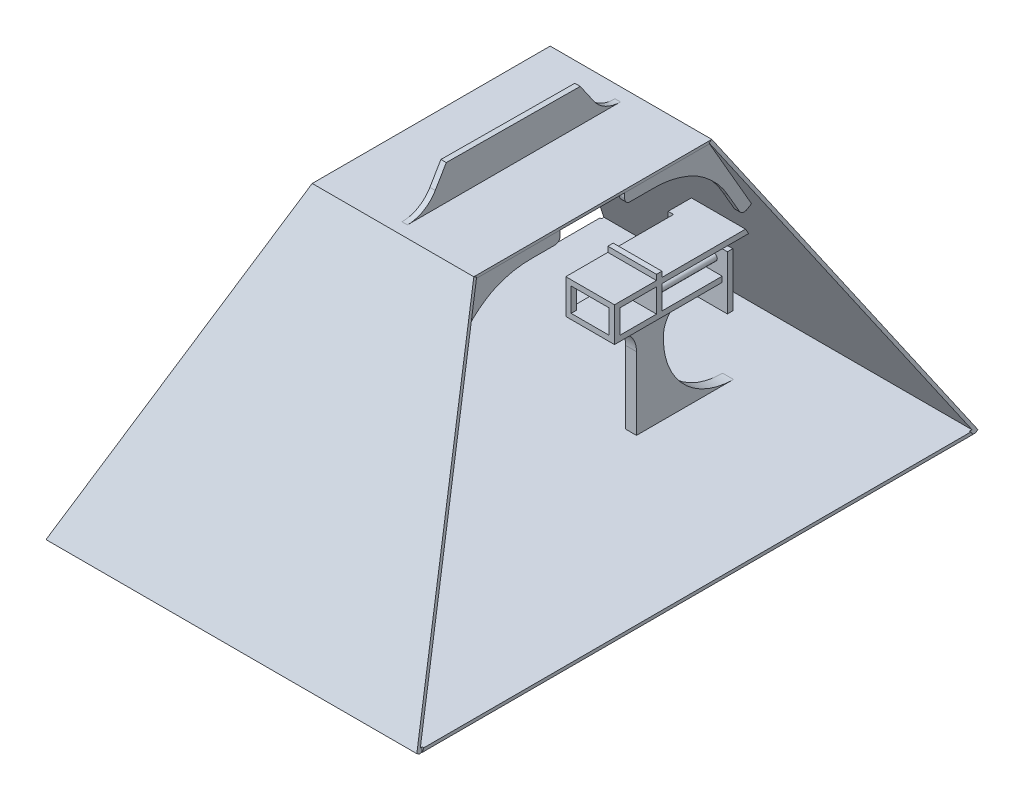
from build123d import *

# Parameters (mm, degrees)
SKETCH3_W                       = 344.153207785
SKETCH3_H                       = 300
BOSS_EXTRUDE1_DEPTH             = 3
BOSS_EXTRUDE2_REACH             = 263.308
SKETCH4_W                       = 5
SKETCH4_H                       = 100
BOSS_EXTRUDE3_REACH             = 104.598
SKETCH5_W                       = 45.211946407
SKETCH5_H                       = 5
BOSS_EXTRUDE3_DIRECTION_2_DEPTH = 100
SKETCH6_W                       = 45.211946407
SKETCH6_H                       = 5
BOSS_EXTRUDE4_DEPTH             = 100
SKETCH7_W                       = 5
SKETCH7_H                       = 50
BOSS_EXTRUDE5_DEPTH             = 50
SKETCH8_W                       = 45.211946407
SKETCH8_H                       = 5
BOSS_EXTRUDE6_DEPTH             = 5
BOSS_EXTRUDE6_DEPTH_BACK        = 27
BOSS_EXTRUDE7_DEPTH             = 3
SKETCH10_R                      = 3
BOSS_EXTRUDE8_DEPTH             = 61
CUT_EXTRUDE3_DEPTH              = 5
CUT_EXTRUDE6_DEPTH              = 5
CUT_EXTRUDE7_DEPTH              = 5
BOSS_EXTRUDE12_REACH            = 105.802
SKETCH25_W                      = 10
SKETCH25_H                      = 25
FILLET4_R                       = 65
SKETCH26_W                      = 37
SKETCH26_H                      = 10
BOSS_EXTRUDE13_DEPTH            = 10
FILLET5_R                       = 23.5
SKETCH27_W                      = 30
SKETCH27_H                      = 10
BOSS_EXTRUDE14_DEPTH            = 10
FILLET6_R                       = 23.5
FILLET7_R                       = 5
SKETCH29_W                      = 5
SKETCH29_H                      = 5
BOSS_EXTRUDE15_DEPTH            = 27
BODY_MOVE_COPY5_ANGLE           = 180
SKETCH30_W                      = 150
SKETCH30_H                      = 220.866025403
BOSS_EXTRUDE16_DEPTH            = 2.5
BOSS_EXTRUDE17_DEPTH            = 5
BOSS_EXTRUDE18_DEPTH            = 5
SKETCH36_W                      = 50
SKETCH36_H                      = 50
BOSS_EXTRUDE19_DEPTH            = 10
SKETCH37_W                      = 5
SKETCH37_H                      = 164.861239663
BOSS_EXTRUDE20_DEPTH            = 70
CUT_EXTRUDE8_DEPTH              = 170.576603893
CUT_EXTRUDE8_DEPTH_BACK         = 175.576603893
FILLET8_R                       = 30
FILLET9_R                       = 30
BOSS_EXTRUDE21_DEPTH            = 5
BOSS_EXTRUDE21_DEPTH_BACK       = 5
CUT_EXTRUDE9_DEPTH              = 5
FILLET10_R                      = 5


with BuildPart() as part:
    # Sketch3 → Boss-Extrude1 (new body)
    with BuildSketch(Plane(origin=(0, 0, 0), x_dir=(1, 0, 0), z_dir=(0, 0.5, 0.866025404))):
        with Locations((132.076603893, 150)):
            Rectangle(SKETCH3_W, SKETCH3_H)
    extrude(amount=BOSS_EXTRUDE1_DEPTH)

    # Sketch4 → Boss-Extrude2 (add, up to next)
    with BuildSketch(Plane(origin=(0, 0, 0), x_dir=(1, 0, 0), z_dir=(0, 1, 0)), mode=Mode.PRIVATE) as boss_extrude2_sk1:
        with Locations((142.5, 50)):
            Rectangle(SKETCH4_W, SKETCH4_H)
    boss_extrude2_tool1 = extrude(boss_extrude2_sk1.sketch, amount=BOSS_EXTRUDE2_REACH, mode=Mode.PRIVATE) - part.part
    add(boss_extrude2_tool1.solids().sort_by_distance((142.5, 0, -50))[0])

    # Sketch5 → Boss-Extrude3 (add, up to next)
    with BuildSketch(Plane(origin=(0, 0, -100), x_dir=(-1, 0, 0), z_dir=(0, 0, -1)), mode=Mode.PRIVATE) as boss_extrude3_sk1:
        with Locations((-117.394026797, 133.302142119)):
            Rectangle(SKETCH5_W, SKETCH5_H)
    boss_extrude3_tool1 = extrude(boss_extrude3_sk1.sketch, amount=-BOSS_EXTRUDE3_REACH, mode=Mode.PRIVATE) - part.part
    add(boss_extrude3_tool1.solids().sort_by_distance((117.394027, 133.302142, -100))[0])

    # Sketch5 → Boss-Extrude3 direction 2 (add)
    with BuildSketch(Plane(origin=(0, 0, -100), x_dir=(-1, 0, 0), z_dir=(0, 0, -1))):
        with Locations((-117.394026797, 133.302142119)):
            Rectangle(SKETCH5_W, SKETCH5_H)
    extrude(amount=BOSS_EXTRUDE3_DIRECTION_2_DEPTH)



with BuildPart() as body_2:
    # Sketch6 → Boss-Extrude4 (new body)
    with BuildSketch(Plane(origin=(0, 0, -100), x_dir=(-1, 0, 0), z_dir=(0, 0, -1))):
        with Locations((-117.394026797, 106.302142119)):
            Rectangle(SKETCH6_W, SKETCH6_H)
    extrude(amount=BOSS_EXTRUDE4_DEPTH)


with BuildPart() as part_1:
    add(part.part)

    add(body_2.part)  # Boss-Extrude5 merges body 2
    # Sketch7 → Boss-Extrude5 (add)
    with BuildSketch(Plane.ZY.offset(-140)):
        with Locations((-97.5, 105.802142119)):
            Rectangle(SKETCH7_W, SKETCH7_H)
    extrude(amount=BOSS_EXTRUDE5_DEPTH)

    # Sketch8 → Boss-Extrude6 (add, two sides)
    with BuildSketch(Plane(origin=(0, 135.802142119, 0), x_dir=(1, 0, 0), z_dir=(0, 1, 0))) as boss_extrude6_sk:
        with Locations((117.394026797, 158.5)):
            Rectangle(SKETCH8_W, SKETCH8_H)
    extrude(amount=BOSS_EXTRUDE6_DEPTH)
    extrude(boss_extrude6_sk.sketch, amount=-BOSS_EXTRUDE6_DEPTH_BACK)

    # Sketch9 → Boss-Extrude7 (add)
    with BuildSketch(Plane.XZ):
        Polygon((0, 0), (-40, 0), (-40, -400), (304.153207785, -400), (304.153207785, 0), align=None)
    extrude(amount=-BOSS_EXTRUDE7_DEPTH)

    # Sketch10 → Boss-Extrude8 (add)
    with BuildSketch(Plane(origin=(0, 0, -161), x_dir=(-1, 0, 0), z_dir=(0, 0, -1))):
        with Locations((-132.394026796, 120.490799146)):
            Circle(SKETCH10_R)
        with Locations((-102.394026796, 120.490799146)):
            Circle(SKETCH10_R)
    extrude(amount=-BOSS_EXTRUDE8_DEPTH)

    # Sketch20 → Cut-Extrude3 (cut)
    with BuildSketch(Plane.ZY.offset(-140)):
        Polygon((-100, 135.802142119), (-100, 173.205080757), (-78.405403309, 135.802142119), align=None)
    extrude(amount=-CUT_EXTRUDE3_DEPTH, mode=Mode.SUBTRACT)

    # Sketch23 → Cut-Extrude6 (cut)
    with BuildSketch(Plane(origin=(0, 1.5, 2.598076211), x_dir=(1, 0, 0), z_dir=(0, 0.5, 0.866025404))):
        Polygon((207.076603893, 300), (304.153207785, 300), (304.153207785, 0), align=None)
        Polygon((-40, 300), (57.076603893, 300), (-40, 0), align=None)
    extrude(amount=-CUT_EXTRUDE6_DEPTH, mode=Mode.SUBTRACT)

    # Sketch24 → Cut-Extrude7 (cut)
    with BuildSketch(Plane.ZY.offset(-140)):
        Polygon((-100, 80.802142119), (-46.651138504, 80.802142119), (-1.732050808, 3), (-100, 3), align=None)
    extrude(amount=-CUT_EXTRUDE7_DEPTH, mode=Mode.SUBTRACT)

    # Sketch25 → Boss-Extrude12 (add, up to next)
    with BuildSketch(Plane.XZ.offset(-103.802142119), mode=Mode.PRIVATE) as boss_extrude12_sk1:
        with Locations((117.394026796, -149.5)):
            Rectangle(SKETCH25_W, SKETCH25_H)
    boss_extrude12_tool1 = extrude(boss_extrude12_sk1.sketch, amount=BOSS_EXTRUDE12_REACH, mode=Mode.PRIVATE) - part_1.part
    add(boss_extrude12_tool1.solids().sort_by_distance((117.394027, 103.802142, -149.5))[0])

    # Fillet4
    fillet4_edges = [part_1.edges().sort_by_distance(p)[0] for p in [
        (117.394026796, 3, -137),
    ]]
    fillet(fillet4_edges, radius=FILLET4_R)

    # Sketch26 → Boss-Extrude13 (add)
    with BuildSketch(Plane.ZY.offset(-112.394026796)):
        with Locations((-118.5, 98.802142119)):
            Rectangle(SKETCH26_W, SKETCH26_H)
    extrude(amount=-BOSS_EXTRUDE13_DEPTH)

    # Fillet5
    fillet5_edges = [part_1.edges().sort_by_distance(p)[0] for p in [
        (117.394026796, 93.802142119, -137),
    ]]
    fillet(fillet5_edges, radius=FILLET5_R)

    # Sketch27 → Boss-Extrude14 (add)
    with BuildSketch(Plane.ZY.offset(-112.394026796)):
        with Locations((-177, 98.802142119)):
            Rectangle(SKETCH27_W, SKETCH27_H)
    extrude(amount=-BOSS_EXTRUDE14_DEPTH)

    # Fillet6
    fillet6_edges = [part_1.edges().sort_by_distance(p)[0] for p in [
        (117.394026796, 93.802142119, -162),
    ]]
    fillet(fillet6_edges, radius=FILLET6_R)

    # Fillet7
    fillet7_edges = [part_1.edges().sort_by_distance(p)[0] for p in [
        (117.394026796, 93.802142119, -192),
    ]]
    fillet(fillet7_edges, radius=FILLET7_R)

    # Sketch29 → Boss-Extrude15 (add)
    with BuildSketch(Plane(origin=(0, 135.802142119, 0), x_dir=(1, 0, 0), z_dir=(0, 1, 0))):
        with Locations((97.288053593, 197.5)):
            Rectangle(SKETCH29_W, SKETCH29_H)
        with Locations((137.5, 197.5)):
            Rectangle(SKETCH29_W, SKETCH29_H)
    extrude(amount=-BOSS_EXTRUDE15_DEPTH)


with BuildPart() as body_2_2:
    # Body-Move_Copy5: copy of part
    add(part_1.part.rotate(Axis((132.076603893, 0, -257.834936491), (0, 1, 0)), BODY_MOVE_COPY5_ANGLE))

    # Combine2: union part
    add(part_1.part)

    # Sketch30 → Boss-Extrude16 (add)
    with BuildSketch(Plane(origin=(0, 261.307621135, 0), x_dir=(-1, 0, 0), z_dir=(0, -1, 0))):
        with Locations((-132.076603893, 257.834936491)):
            Rectangle(SKETCH30_W, SKETCH30_H)
    extrude(amount=BOSS_EXTRUDE16_DEPTH)

    # Sketch33 → Boss-Extrude17 (add)
    with BuildSketch(Plane.ZY.offset(-61.759180989)):
        with BuildLine():
            Line((-293.511616106, 258.807621135), (-293.511616106, 248.807621135))
            Line((-293.511616106, 248.807621135), (-319.511616106, 248.807621135))
            add(Edge.make_bspline(
                [(-319.511616106, 248.807621135), (-339.42072005, 249.064199422), (-358.182678994, 239.839420743)],
                knots=[0, 0, 0, 1, 1, 1], degree=2))
            add(Edge.make_bspline(
                [(-385.284899804, 210.833398087), (-375.619324217, 228.267374507), (-358.182678994, 239.839420743)],
                knots=[0, 0, 0, 1, 1, 1], degree=2))
            Line((-385.284899804, 210.833398087), (-398.284899804, 188.316737588))
            Line((-398.284899804, 188.316737588), (-406.945153842, 193.316737588))
            Line((-406.945153842, 193.316737588), (-369.133974596, 258.807621135))
            Line((-369.133974596, 258.807621135), (-293.511616106, 258.807621135))
        make_face()
        with BuildLine():
            Line((-225.045008221, 248.807621135), (-199.045008221, 248.807621135))
            add(Edge.make_bspline(
                [(-199.045008221, 248.807621135), (-179.135904277, 249.064199422), (-160.373945333, 239.839420743)],
                knots=[0, 0, 0, 1, 1, 1], degree=2))
            add(Edge.make_bspline(
                [(-133.271724523, 210.833398087), (-142.93730011, 228.267374507), (-160.373945333, 239.839420743)],
                knots=[0, 0, 0, 1, 1, 1], degree=2))
            Line((-133.271724523, 210.833398087), (-120.271724523, 188.316737588))
            Line((-120.271724523, 188.316737588), (-111.611470486, 193.316737588))
            Line((-111.611470486, 193.316737588), (-149.422649731, 258.807621135))
            Line((-149.422649731, 258.807621135), (-225.045008221, 258.807621135))
            Line((-225.045008221, 258.807621135), (-225.045008221, 248.807621135))
        make_face()
    extrude(amount=BOSS_EXTRUDE17_DEPTH)

    # Sketch34 → Boss-Extrude18 (add)
    with BuildSketch(Plane(origin=(201.759180989, 0, 0), x_dir=(0, 0, -1), z_dir=(1, 0, 0))):
        with BuildLine():
            Line((227.931759567, 248.807621135), (227.931759567, 258.807621135))
            Line((227.931759567, 258.807621135), (149.422649731, 258.807621135))
            Line((149.422649731, 258.807621135), (110.168094813, 190.816737588))
            Line((110.168094813, 190.816737588), (118.82834885, 185.816737588))
            Line((118.82834885, 185.816737588), (131.82834885, 208.333398087))
            add(Edge.make_bspline(
                [(131.82834885, 208.333398087), (141.486660945, 225.760201331), (158.9283172, 237.208497265)],
                knots=[0, 0, 0, 0.942247547, 0.942247547, 0.942247547], degree=2))
            add(Edge.make_bspline(
                [(160.501142617, 238.218765674), (159.971256631, 237.89010091), (159.446879089, 237.553364455), (158.9283172, 237.208497265)],
                knots=[0.958206549, 0.958206549, 0.958206549, 0.958206549, 1, 1, 1, 1], degree=3))
            add(Edge.make_bspline(
                [(201.931759567, 248.807621135), (187.694288, 249.046552284), (172.649941369, 245.754126435), (160.501142617, 238.218765674)],
                knots=[0, 0, 0, 0, 0.958206549, 0.958206549, 0.958206549, 0.958206549], degree=3))
            Line((201.931759567, 248.807621135), (227.931759567, 248.807621135))
        make_face()
        with BuildLine():
            Line((287.738113414, 258.807621135), (287.738113414, 248.807621135))
            Line((287.738113414, 248.807621135), (313.738113414, 248.807621135))
            add(Edge.make_bspline(
                [(313.738113414, 248.807621135), (334.870899638, 249.142282618), (354.574239811, 238.589420743)],
                knots=[0, 0, 0, 1, 1, 1], degree=2))
            add(Edge.make_bspline(
                [(383.841524131, 208.333398087), (373.591232556, 226.828328952), (354.574239811, 238.589420743)],
                knots=[0, 0, 0, 1, 1, 1], degree=2))
            Line((383.841524131, 208.333398087), (396.841524131, 185.816737588))
            Line((396.841524131, 185.816737588), (405.501778169, 190.816737588))
            Line((405.501778169, 190.816737588), (366.24722325, 258.807621135))
            Line((366.24722325, 258.807621135), (287.738113414, 258.807621135))
        make_face()
    extrude(amount=BOSS_EXTRUDE18_DEPTH)

    # Sketch36 → Boss-Extrude19 (add)
    with BuildSketch(Plane.XZ.offset(-258.807621135)):
        with Locations((132.076603893, -257.834936491)):
            Rectangle(SKETCH36_W, SKETCH36_H)
    extrude(amount=BOSS_EXTRUDE19_DEPTH)

    # Sketch37 → Boss-Extrude20 (add)
    with BuildSketch(Plane(origin=(0, 261.307621135, 0), x_dir=(1, 0, 0), z_dir=(0, 1, 0))):
        with Locations((132.076603893, 257.834936491)):
            Rectangle(SKETCH37_W, SKETCH37_H)
    extrude(amount=BOSS_EXTRUDE20_DEPTH)

    # Sketch38 → Cut-Extrude8 (cut, two sides)
    with BuildSketch(Plane(origin=(134.576603893, 0, 0), x_dir=(0, 0, -1), z_dir=(1, 0, 0))) as cut_extrude8_sk:
        Polygon((175.404316659, 331.307621135), (175.404316659, 261.307621135), (204.559344242, 310.710387074), (305.992642377, 310.710387074), (340.265556322, 261.307621135), (340.265556322, 331.307621135), align=None)
    extrude(amount=CUT_EXTRUDE8_DEPTH, mode=Mode.SUBTRACT)
    extrude(cut_extrude8_sk.sketch, amount=-CUT_EXTRUDE8_DEPTH_BACK, mode=Mode.SUBTRACT)

    # Fillet8
    fillet8_edges = [body_2_2.edges().sort_by_distance(p)[0] for p in [
        (132.076603893, 261.307621135, -340.265556322),
    ]]
    fillet(fillet8_edges, radius=FILLET8_R)

    # Fillet9
    fillet9_edges = [body_2_2.edges().sort_by_distance(p)[0] for p in [
        (132.076603893, 261.307621135, -175.404316659),
    ]]
    fillet(fillet9_edges, radius=FILLET9_R)

    # Sketch41 → Boss-Extrude21 (add, two sides)
    with BuildSketch(Plane.ZY.offset(-131.759180989)) as boss_extrude21_sk:
        with BuildLine():
            Line((-290.62486476, 258.807621135), (-290.62486476, 248.807621135))
            Line((-290.62486476, 248.807621135), (-316.62486476, 248.807621135))
            add(Edge.make_bspline(
                [(-316.62486476, 248.807621135), (-336.533968704, 249.064199422), (-355.295927648, 239.839420743)],
                knots=[0, 0, 0, 1, 1, 1], degree=2))
            add(Edge.make_bspline(
                [(-382.398148458, 210.833398087), (-372.732572871, 228.267374507), (-355.295927648, 239.839420743)],
                knots=[0, 0, 0, 1, 1, 1], degree=2))
            Line((-382.398148458, 210.833398087), (-395.398148458, 188.316737588))
            Line((-395.398148458, 188.316737588), (-404.058402496, 193.316737588))
            Line((-404.058402496, 193.316737588), (-366.24722325, 258.807621135))
            Line((-366.24722325, 258.807621135), (-290.62486476, 258.807621135))
        make_face()
        with BuildLine():
            Line((-222.158256875, 248.807621135), (-196.158256875, 248.807621135))
            add(Edge.make_bspline(
                [(-196.158256875, 248.807621135), (-176.249152931, 249.064199422), (-157.487193987, 239.839420743)],
                knots=[0, 0, 0, 1, 1, 1], degree=2))
            add(Edge.make_bspline(
                [(-130.384973177, 210.833398087), (-140.050548764, 228.267374507), (-157.487193987, 239.839420743)],
                knots=[0, 0, 0, 1, 1, 1], degree=2))
            Line((-130.384973177, 210.833398087), (-117.384973177, 188.316737588))
            Line((-117.384973177, 188.316737588), (-108.72471914, 193.316737588))
            Line((-108.72471914, 193.316737588), (-146.535898385, 258.807621135))
            Line((-146.535898385, 258.807621135), (-222.158256875, 258.807621135))
            Line((-222.158256875, 258.807621135), (-222.158256875, 248.807621135))
        make_face()
    extrude(amount=BOSS_EXTRUDE21_DEPTH)
    extrude(boss_extrude21_sk.sketch, amount=-BOSS_EXTRUDE21_DEPTH_BACK)

    # Sketch42 → Cut-Extrude9 (cut)
    with BuildSketch(Plane.ZY.offset(-129.576603893)):
        Polygon((-318.654527785, 292.458884964), (-194.334970933, 293.385336703), (-204.559344242, 310.710387074), (-305.992642377, 310.710387074), align=None)
    extrude(amount=-CUT_EXTRUDE9_DEPTH, mode=Mode.SUBTRACT)

    # Fillet10
    fillet10_edges = [body_2_2.edges().sort_by_distance(p)[0] for p in [
        (59.259180989, 188.316737588, -398.284899804),
        (59.259180989, 248.807621135, -293.511616106),
        (59.259180989, 248.807621135, -225.045008221),
        (59.259180989, 188.316737588, -120.271724523),
        (204.259180989, 248.807621135, -227.931759567),
        (204.259180989, 185.816737588, -118.82834885),
        (204.259180989, 185.816737588, -396.841524131),
        (204.259180989, 248.807621135, -287.738113414),
        (131.759180989, 248.807621135, -290.62486476),
        (131.759180989, 188.316737588, -395.398148458),
        (131.759180989, 188.316737588, -117.384973177),
        (131.759180989, 248.807621135, -222.158256875),
    ]]
    fillet(fillet10_edges, radius=FILLET10_R)


solid = body_2_2.part
